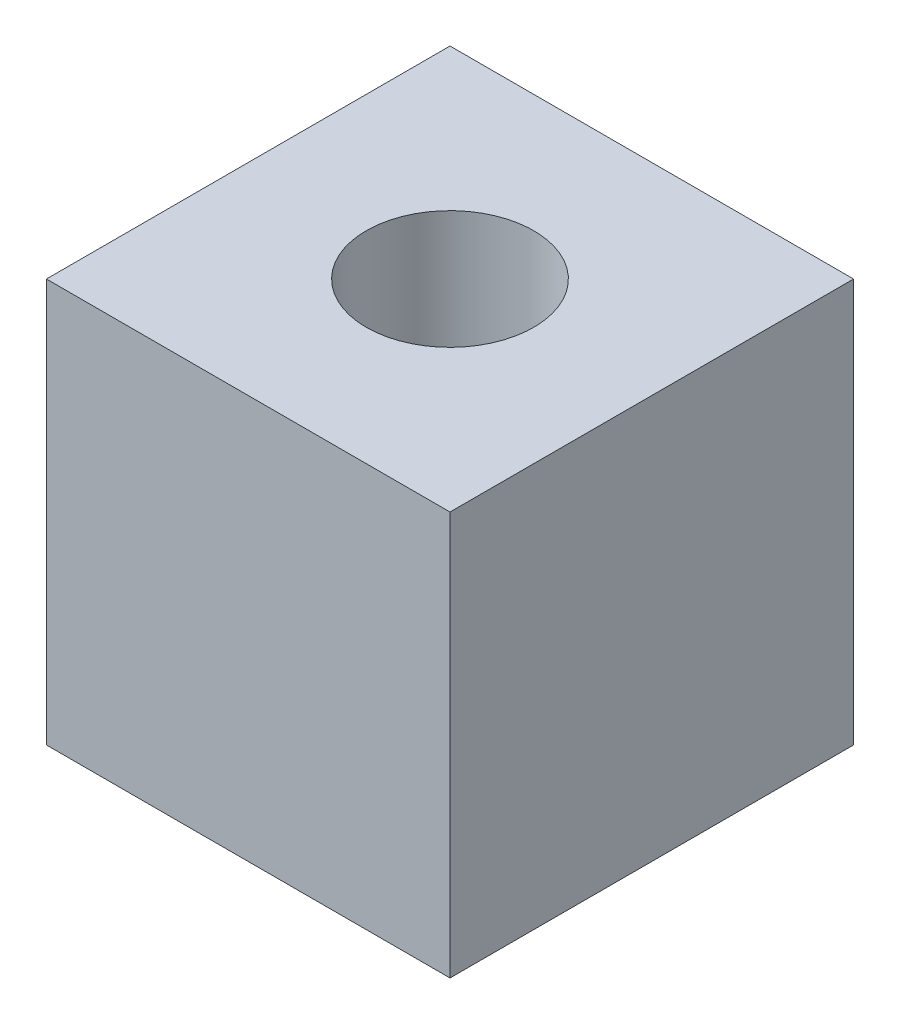
from build123d import *

# Parameters (mm, degrees)
SKETCH1_W           = 20
SKETCH1_H           = 20
BOSS_EXTRUDE1_DEPTH = 20
SKETCH2_R           = 4.15
CUT_EXTRUDE1_DEPTH  = 21


with BuildPart() as part:
    # Sketch1 → Boss-Extrude1 (new body)
    with BuildSketch(Plane(origin=(0, 0, 0), x_dir=(1, 0, 0), z_dir=(0, 1, 0))):
        with Locations((-10, 10)):
            Rectangle(SKETCH1_W, SKETCH1_H)
    extrude(amount=BOSS_EXTRUDE1_DEPTH)

    # Sketch2 → Cut-Extrude1 (cut, through all)
    with BuildSketch(Plane(origin=(0, 20, 0), x_dir=(1, 0, 0), z_dir=(0, 1, 0))):
        with Locations((-10, 10)):
            Circle(SKETCH2_R)
    extrude(amount=-CUT_EXTRUDE1_DEPTH, mode=Mode.SUBTRACT)


solid = part.part
